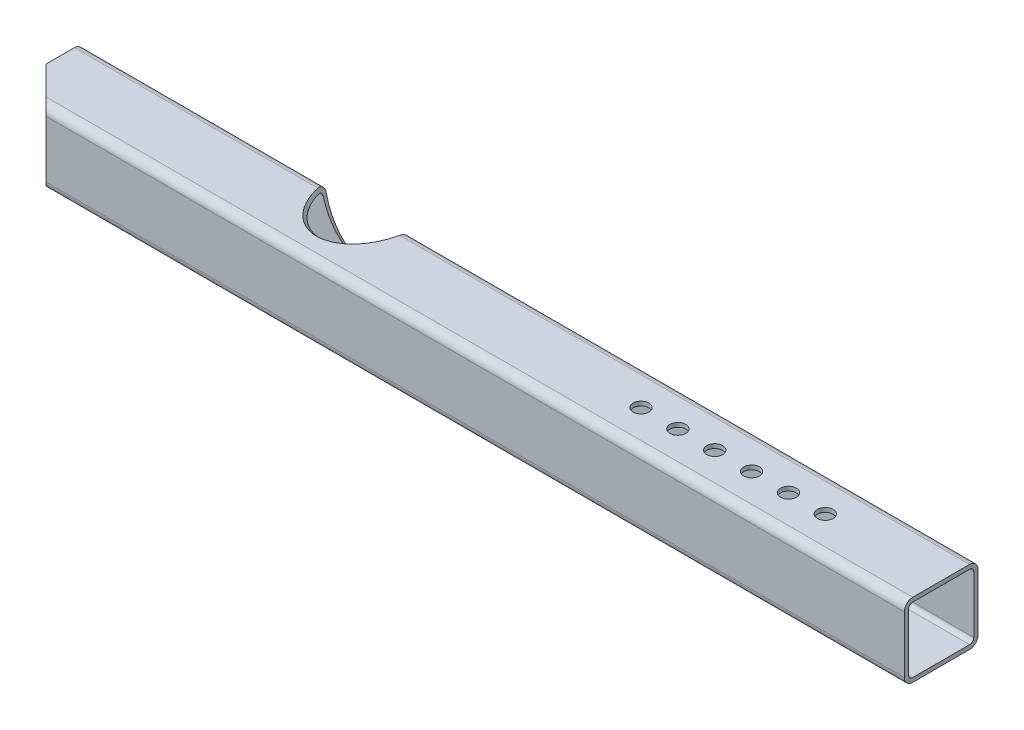
from build123d import *

# Parameters (mm, degrees)
EL_MENT_M_CANO_SOUD_1_DEPTH = 850
ESQUISSE3_R                 = 7.5
ENL_V_MAT_EXTRU_2_DEPTH     = 90
ENL_V_MAT_EXTRU_3_DEPTH     = 71
ESQUISSE7_R                 = 40.75
ENL_V_MAT_EXTRU_5_DEPTH     = 75


with BuildPart() as part:
    # tube carré1 → Elément mécano-soudé1 (new body)
    with BuildSketch(Plane.YZ.offset(-425)):
        with BuildLine():
            Line((-27, 35), (27, 35))
            ThreePointArc((27, 35), (32.656854249, 32.656854249), (35, 27))
            Line((35, 27), (35, -27))
            ThreePointArc((35, -27), (32.656854249, -32.656854249), (27, -35))
            Line((27, -35), (-27, -35))
            ThreePointArc((-27, -35), (-32.656854249, -32.656854249), (-35, -27))
            Line((-35, -27), (-35, 27))
            ThreePointArc((-35, 27), (-32.656854249, 32.656854249), (-27, 35))
        make_face()
        with BuildLine():
            Line((-27, 31), (27, 31))
            ThreePointArc((27, 31), (29.828427336, 29.828426914), (31, 26.999999403))
            Line((31, 26.999999403), (31, -26.999999403))
            ThreePointArc((31, -26.999999403), (29.828427336, -29.828426914), (27, -31))
            Line((27, -31), (-27, -31))
            ThreePointArc((-27, -31), (-29.828427336, -29.828426914), (-31, -26.999999403))
            Line((-31, -26.999999403), (-31, 26.999999403))
            ThreePointArc((-31, 26.999999403), (-29.828427336, 29.828426914), (-27, 31))
        make_face(mode=Mode.SUBTRACT)
    extrude(amount=EL_MENT_M_CANO_SOUD_1_DEPTH)

    # Esquisse3 → Enlèv. mat.-Extru.2 (cut)
    with BuildSketch(Plane(origin=(0, 35, 0), x_dir=(1, 0, 0), z_dir=(0, 1, 0))):
        with Locations(Location((315, 0, 0), (0, 0, 270))):  # turned: the seam where the file's is
            Circle(ESQUISSE3_R)
        with Locations(Location((280, 0, 0), (0, 0, 270))):  # turned: the seam where the file's is
            Circle(ESQUISSE3_R)
        with Locations(Location((245, 0, 0), (0, 0, 270))):  # turned: the seam where the file's is
            Circle(ESQUISSE3_R)
        with Locations(Location((210, 0, 0), (0, 0, 270))):  # turned: the seam where the file's is
            Circle(ESQUISSE3_R)
        with Locations(Location((175, 0, 0), (0, 0, 270))):  # turned: the seam where the file's is
            Circle(ESQUISSE3_R)
        with Locations(Location((140, 0, 0), (0, 0, 270))):  # turned: the seam where the file's is
            Circle(ESQUISSE3_R)
    extrude(amount=-ENL_V_MAT_EXTRU_2_DEPTH, mode=Mode.SUBTRACT)

    # Esquisse5 → Enlèv. mat.-Extru.3 (cut, through all)
    with BuildSketch(Plane(origin=(0, 35, 0), x_dir=(1, 0, 0), z_dir=(0, 1, 0))):
        Polygon((-425, 0), (-390, -35), (-425, -35), align=None)
    extrude(amount=-ENL_V_MAT_EXTRU_3_DEPTH, mode=Mode.SUBTRACT)

    # Esquisse7 → Enlèv. mat.-Extru.5 (cut, symmetric)
    with BuildSketch(Plane(origin=(0, 0, 0), x_dir=(1, 0, 0), z_dir=(-1e-09, 0.707106781, 0.707106781))):
        with Locations((-154.999999996, 56.183766184)):
            Circle(ESQUISSE7_R)
    extrude(amount=ENL_V_MAT_EXTRU_5_DEPTH, both=True, mode=Mode.SUBTRACT)


solid = part.part
